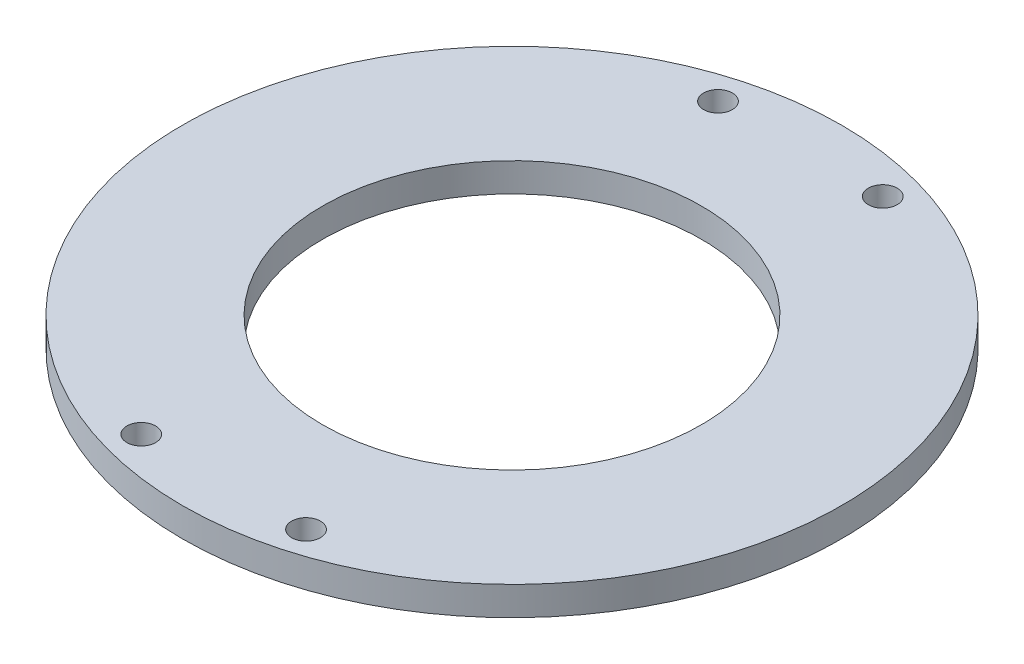
from build123d import *

# Parameters (mm, degrees)
SKETCH1_R           = 40
SKETCH1_R_2         = 1.75
SKETCH1_R_3         = 23
BOSS_EXTRUDE1_DEPTH = 3.5


with BuildPart() as part:
    # Sketch1 → Boss-Extrude1 (new body)
    with BuildSketch(Plane(origin=(0, 0, 0), x_dir=(1, 0, 0), z_dir=(0, 1, 0))):
        Circle(SKETCH1_R)
        with Locations((10, 35)):
            Circle(SKETCH1_R_2, mode=Mode.SUBTRACT)
        with Locations((-10, 35)):
            Circle(SKETCH1_R_2, mode=Mode.SUBTRACT)
        with Locations((10, -35)):
            Circle(SKETCH1_R_2, mode=Mode.SUBTRACT)
        with Locations((-10, -35)):
            Circle(SKETCH1_R_2, mode=Mode.SUBTRACT)
        Circle(SKETCH1_R_3, mode=Mode.SUBTRACT)
    extrude(amount=BOSS_EXTRUDE1_DEPTH)


solid = part.part
